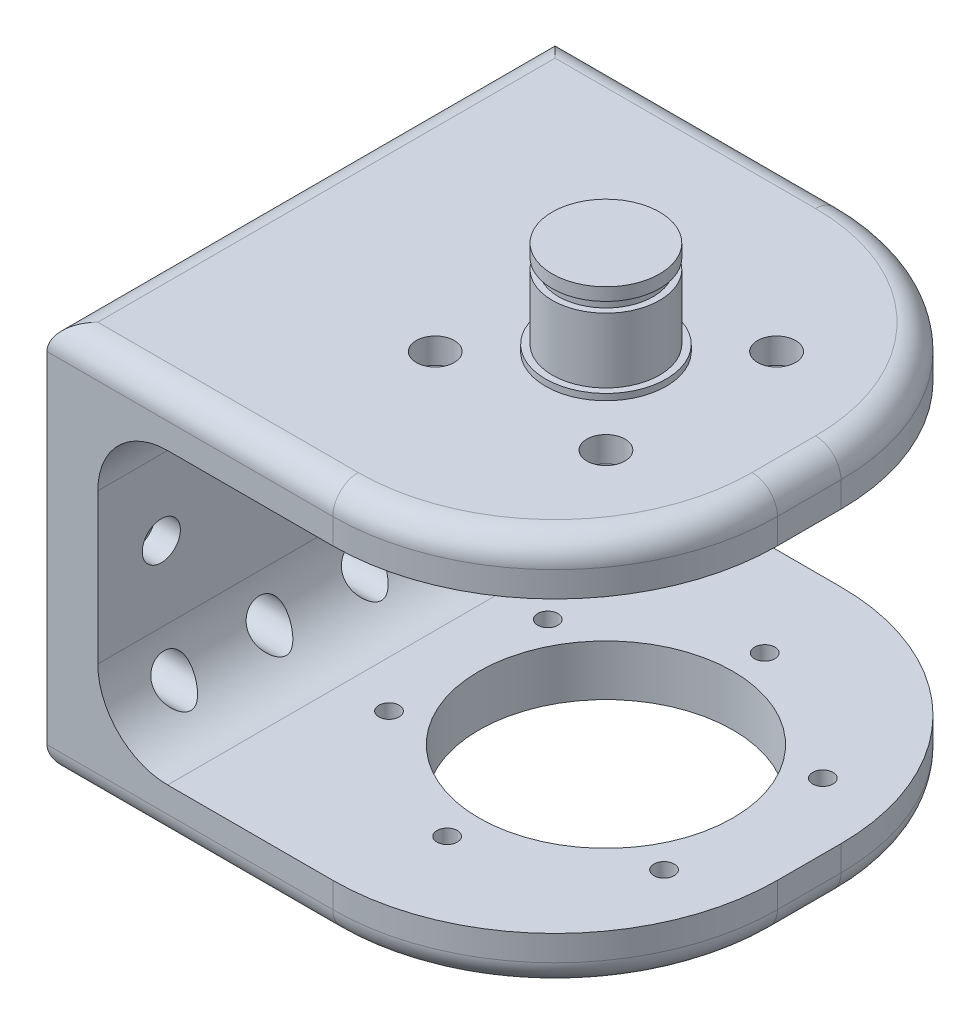
from build123d import *

# Parameters (mm, degrees)
SKETCH_1_W          = 80
SKETCH_1_H          = 80
EXTRUDE_1_DEPTH     = 8
SKETCH_2_W          = 8
SKETCH_2_H          = 80
EXTRUDE_2_DEPTH     = 53.6
SKETCH_5_W          = 80
SKETCH_5_H          = 8
EXTRUDE_3_DEPTH     = 72
SKETCH_4_R          = 1.6
SKETCH_4_R_2        = 20
CUT_EXTRUDE_1_DEPTH = 9
CUT_EXTRUDE_3_REACH = 63.6
SKETCH_7_R          = 1.6
FILLET_3_R          = 35
FILLET_4_R          = 11
SKETCH_6_R          = 1.6
CUT_EXTRUDE_2_DEPTH = 81
SKETCH_8_R          = 8.45
EXTRUDE_4_DEPTH     = 14.8
SKETCH_10_R         = 8.45
SKETCH_10_R_2       = 7.45
CUT_EXTRUDE_4_DEPTH = 1.6
CUT_EXTRUDE_5_REACH = 78
SKETCH_12_R         = 3
SKETCH_14_R         = 3
CUT_EXTRUDE_6_DEPTH = 4
SKETCH_15_R         = 3
CUT_EXTRUDE_7_DEPTH = 4
SKETCH_16_R         = 9.5
EXTRUDE_5_DEPTH     = 1
FILLET2_R           = 4


with BuildPart() as part:
    # 草图1 → 凸台-拉伸1 (new body)
    with BuildSketch(Plane(origin=(0, 0, 0), x_dir=(1, 0, 0), z_dir=(0, 1, 0))):
        Rectangle(SKETCH_1_W, SKETCH_1_H)
    extrude(amount=EXTRUDE_1_DEPTH)

    # 草图2 → 凸台-拉伸2 (add)
    with BuildSketch(Plane(origin=(0, 8, 0), x_dir=(1, 0, 0), z_dir=(0, 1, 0))):
        with Locations((-36, 0)):
            Rectangle(SKETCH_2_W, SKETCH_2_H)
    extrude(amount=EXTRUDE_2_DEPTH)

    # 草图5 → 凸台-拉伸3 (add, through all)
    with BuildSketch(Plane(origin=(-32, 0, 0), x_dir=(0, 0, -1), z_dir=(1, 0, 0))):
        with Locations((0, 57.6)):
            Rectangle(SKETCH_5_W, SKETCH_5_H)
    extrude(amount=EXTRUDE_3_DEPTH)

    # 草图4 → 切除-拉伸1 (cut, through all)
    with BuildSketch(Plane(origin=(0, 8, 0), x_dir=(1, 0, 0), z_dir=(0, 1, 0))):
        with Locations((8, 25)):
            Circle(SKETCH_4_R)
        with Locations((-13.650635095, 12.5)):
            Circle(SKETCH_4_R)
        with Locations((-13.650635095, -12.5)):
            Circle(SKETCH_4_R)
        with Locations((8, -25)):
            Circle(SKETCH_4_R)
        with Locations((8, 0)):
            Circle(SKETCH_4_R_2)
        with Locations((29.650635095, -12.5)):
            Circle(SKETCH_4_R)
        with Locations((29.650635095, 12.5)):
            Circle(SKETCH_4_R)
    extrude(amount=-CUT_EXTRUDE_1_DEPTH, mode=Mode.SUBTRACT)

    # 草图7 → 切除-拉伸3 (cut, up to next)
    with BuildSketch(Plane(origin=(0, 61.6, 0), x_dir=(1, 0, 0), z_dir=(0, 1, 0)), mode=Mode.PRIVATE) as cut_extrude_3_sk1:
        with Locations((-5.435028843, 13.435028843)):
            Circle(SKETCH_7_R)
    cut_extrude_3_tool1 = extrude(cut_extrude_3_sk1.sketch, amount=-CUT_EXTRUDE_3_REACH, mode=Mode.PRIVATE) & part.part
    add(cut_extrude_3_tool1.solids().sort_by_distance((-5.435029, 61.6, -13.435029))[0], mode=Mode.SUBTRACT)
    # 草图7 → 切除-拉伸3 (cut, up to next)
    with BuildSketch(Plane(origin=(0, 61.6, 0), x_dir=(1, 0, 0), z_dir=(0, 1, 0)), mode=Mode.PRIVATE) as cut_extrude_3_sk2:
        with Locations((21.435028843, 13.435028843)):
            Circle(SKETCH_7_R)
    cut_extrude_3_tool2 = extrude(cut_extrude_3_sk2.sketch, amount=-CUT_EXTRUDE_3_REACH, mode=Mode.PRIVATE) & part.part
    add(cut_extrude_3_tool2.solids().sort_by_distance((21.435029, 61.6, -13.435029))[0], mode=Mode.SUBTRACT)
    # 草图7 → 切除-拉伸3 (cut, up to next)
    with BuildSketch(Plane(origin=(0, 61.6, 0), x_dir=(1, 0, 0), z_dir=(0, 1, 0)), mode=Mode.PRIVATE) as cut_extrude_3_sk3:
        with Locations((21.435028843, -13.435028843)):
            Circle(SKETCH_7_R)
    cut_extrude_3_tool3 = extrude(cut_extrude_3_sk3.sketch, amount=-CUT_EXTRUDE_3_REACH, mode=Mode.PRIVATE) & part.part
    add(cut_extrude_3_tool3.solids().sort_by_distance((21.435029, 61.6, 13.435029))[0], mode=Mode.SUBTRACT)
    # 草图7 → 切除-拉伸3 (cut, up to next)
    with BuildSketch(Plane(origin=(0, 61.6, 0), x_dir=(1, 0, 0), z_dir=(0, 1, 0)), mode=Mode.PRIVATE) as cut_extrude_3_sk4:
        with Locations((-5.435028843, -13.435028843)):
            Circle(SKETCH_7_R)
    cut_extrude_3_tool4 = extrude(cut_extrude_3_sk4.sketch, amount=-CUT_EXTRUDE_3_REACH, mode=Mode.PRIVATE) & part.part
    add(cut_extrude_3_tool4.solids().sort_by_distance((-5.435029, 61.6, 13.435029))[0], mode=Mode.SUBTRACT)

    # 圆角3
    fillet_3_edges = [part.edges().sort_by_distance(p)[0] for p in [
        (40, 57.6, 40),
        (40, 57.6, -40),
        (40, 4, -40),
        (40, 4, 40),
    ]]
    fillet(fillet_3_edges, radius=FILLET_3_R)

    # 圆角4
    fillet_4_edges = [part.edges().sort_by_distance(p)[0] for p in [
        (-32, 8, 0),
        (-32, 53.6, 0),
    ]]
    fillet(fillet_4_edges, radius=FILLET_4_R)

    # 草图6 → 切除-拉伸2 (cut, through all)
    with BuildSketch(Plane.ZY.offset(40)):
        with Locations((-30, 48.6)):
            Circle(SKETCH_6_R)
        with Locations((30, 48.6)):
            Circle(SKETCH_6_R)
        with Locations((30, 13)):
            Circle(SKETCH_6_R)
        with Locations((-30, 13)):
            Circle(SKETCH_6_R)
        with Locations((-15, 13)):
            Circle(SKETCH_6_R)
        with Locations((0, 13)):
            Circle(SKETCH_6_R)
        with Locations((15, 13)):
            Circle(SKETCH_6_R)
        with Locations((-30, 30.8)):
            Circle(SKETCH_6_R)
        with Locations((30, 30.8)):
            Circle(SKETCH_6_R)
    extrude(amount=-CUT_EXTRUDE_2_DEPTH, mode=Mode.SUBTRACT)

    # 草图8 → 凸台-拉伸4 (add)
    with BuildSketch(Plane(origin=(0, 61.6, 0), x_dir=(1, 0, 0), z_dir=(0, 1, 0))):
        with Locations((8, 0)):
            Circle(SKETCH_8_R)
    extrude(amount=EXTRUDE_4_DEPTH)

    # 草图10 → 切除-拉伸4 (cut)
    with BuildSketch(Plane(origin=(0, 74.4, 0), x_dir=(1, 0, 0), z_dir=(0, 1, 0))):
        with Locations((8, 0)):
            Circle(SKETCH_10_R)
        with Locations((8, 0)):
            Circle(SKETCH_10_R_2, mode=Mode.SUBTRACT)
    extrude(amount=-CUT_EXTRUDE_4_DEPTH, mode=Mode.SUBTRACT)

    # 草图12 → 切除-拉伸5 (cut, up to next)
    with BuildSketch(Plane.ZY.offset(36), mode=Mode.PRIVATE) as cut_extrude_5_sk1:
        with Locations((-30, 48.6)):
            Circle(SKETCH_12_R)
    cut_extrude_5_tool1 = extrude(cut_extrude_5_sk1.sketch, amount=-CUT_EXTRUDE_5_REACH, mode=Mode.PRIVATE) & part.part
    add(cut_extrude_5_tool1.solids().sort_by_distance((-36, 48.6, -30))[0], mode=Mode.SUBTRACT)
    # 草图12 → 切除-拉伸5 (cut, up to next)
    with BuildSketch(Plane.ZY.offset(36), mode=Mode.PRIVATE) as cut_extrude_5_sk2:
        with Locations((30, 48.6)):
            Circle(SKETCH_12_R)
    cut_extrude_5_tool2 = extrude(cut_extrude_5_sk2.sketch, amount=-CUT_EXTRUDE_5_REACH, mode=Mode.PRIVATE) & part.part
    add(cut_extrude_5_tool2.solids().sort_by_distance((-36, 48.6, 30))[0], mode=Mode.SUBTRACT)
    # 草图12 → 切除-拉伸5 (cut, up to next)
    with BuildSketch(Plane.ZY.offset(36), mode=Mode.PRIVATE) as cut_extrude_5_sk3:
        with Locations((30, 13)):
            Circle(SKETCH_12_R)
    cut_extrude_5_tool3 = extrude(cut_extrude_5_sk3.sketch, amount=-CUT_EXTRUDE_5_REACH, mode=Mode.PRIVATE) & part.part
    add(cut_extrude_5_tool3.solids().sort_by_distance((-36, 13, 30))[0], mode=Mode.SUBTRACT)
    # 草图12 → 切除-拉伸5 (cut, up to next)
    with BuildSketch(Plane.ZY.offset(36), mode=Mode.PRIVATE) as cut_extrude_5_sk4:
        with Locations((-30, 13)):
            Circle(SKETCH_12_R)
    cut_extrude_5_tool4 = extrude(cut_extrude_5_sk4.sketch, amount=-CUT_EXTRUDE_5_REACH, mode=Mode.PRIVATE) & part.part
    add(cut_extrude_5_tool4.solids().sort_by_distance((-36, 13, -30))[0], mode=Mode.SUBTRACT)
    # 草图12 → 切除-拉伸5 (cut, up to next)
    with BuildSketch(Plane.ZY.offset(36), mode=Mode.PRIVATE) as cut_extrude_5_sk5:
        with Locations((-15, 13)):
            Circle(SKETCH_12_R)
    cut_extrude_5_tool5 = extrude(cut_extrude_5_sk5.sketch, amount=-CUT_EXTRUDE_5_REACH, mode=Mode.PRIVATE) & part.part
    add(cut_extrude_5_tool5.solids().sort_by_distance((-36, 13, -15))[0], mode=Mode.SUBTRACT)
    # 草图12 → 切除-拉伸5 (cut, up to next)
    with BuildSketch(Plane.ZY.offset(36), mode=Mode.PRIVATE) as cut_extrude_5_sk6:
        with Locations((0, 13)):
            Circle(SKETCH_12_R)
    cut_extrude_5_tool6 = extrude(cut_extrude_5_sk6.sketch, amount=-CUT_EXTRUDE_5_REACH, mode=Mode.PRIVATE) & part.part
    add(cut_extrude_5_tool6.solids().sort_by_distance((-36, 13, 0))[0], mode=Mode.SUBTRACT)
    # 草图12 → 切除-拉伸5 (cut, up to next)
    with BuildSketch(Plane.ZY.offset(36), mode=Mode.PRIVATE) as cut_extrude_5_sk7:
        with Locations((15, 13)):
            Circle(SKETCH_12_R)
    cut_extrude_5_tool7 = extrude(cut_extrude_5_sk7.sketch, amount=-CUT_EXTRUDE_5_REACH, mode=Mode.PRIVATE) & part.part
    add(cut_extrude_5_tool7.solids().sort_by_distance((-36, 13, 15))[0], mode=Mode.SUBTRACT)
    # 草图12 → 切除-拉伸5 (cut, up to next)
    with BuildSketch(Plane.ZY.offset(36), mode=Mode.PRIVATE) as cut_extrude_5_sk8:
        with Locations((-30, 30.8)):
            Circle(SKETCH_12_R)
    cut_extrude_5_tool8 = extrude(cut_extrude_5_sk8.sketch, amount=-CUT_EXTRUDE_5_REACH, mode=Mode.PRIVATE) & part.part
    add(cut_extrude_5_tool8.solids().sort_by_distance((-36, 30.8, -30))[0], mode=Mode.SUBTRACT)
    # 草图12 → 切除-拉伸5 (cut, up to next)
    with BuildSketch(Plane.ZY.offset(36), mode=Mode.PRIVATE) as cut_extrude_5_sk9:
        with Locations((30, 30.8)):
            Circle(SKETCH_12_R)
    cut_extrude_5_tool9 = extrude(cut_extrude_5_sk9.sketch, amount=-CUT_EXTRUDE_5_REACH, mode=Mode.PRIVATE) & part.part
    add(cut_extrude_5_tool9.solids().sort_by_distance((-36, 30.8, 30))[0], mode=Mode.SUBTRACT)

    # 草图14 → 切除-拉伸6 (cut)
    with BuildSketch(Plane(origin=(0, 61.6, 0), x_dir=(1, 0, 0), z_dir=(0, 1, 0))):
        with Locations((-5.435028843, 13.435028843)):
            Circle(SKETCH_14_R)
        with Locations((21.435028843, 13.435028843)):
            Circle(SKETCH_14_R)
        with Locations((21.435028843, -13.435028843)):
            Circle(SKETCH_14_R)
        with Locations((-5.435028843, -13.435028843)):
            Circle(SKETCH_14_R)
    extrude(amount=-CUT_EXTRUDE_6_DEPTH, mode=Mode.SUBTRACT)

    # 草图15 → 切除-拉伸7 (cut)
    with BuildSketch(Plane.XZ):
        with Locations((-13.650635095, 12.5)):
            Circle(SKETCH_15_R)
        with Locations((8, 25)):
            Circle(SKETCH_15_R)
        with Locations((29.650635095, 12.5)):
            Circle(SKETCH_15_R)
        with Locations((29.650635095, -12.5)):
            Circle(SKETCH_15_R)
        with Locations((8, -25)):
            Circle(SKETCH_15_R)
        with Locations((-13.650635095, -12.5)):
            Circle(SKETCH_15_R)
    extrude(amount=-CUT_EXTRUDE_7_DEPTH, mode=Mode.SUBTRACT)

    # 草图16 → 凸台-拉伸5 (add)
    with BuildSketch(Plane(origin=(0, 61.6, 0), x_dir=(1, 0, 0), z_dir=(0, 1, 0))):
        with Locations((8, 0)):
            Circle(SKETCH_16_R)
    extrude(amount=EXTRUDE_5_DEPTH)

    # Fillet2
    fillet2_edges = [part.edges().sort_by_distance(p)[0] for p in [
        (40, 0, 0),
        (29.748737342, 0, -29.748737342),
        (29.748737342, 0, 29.748737342),
        (-40, 61.6, 0),
        (-17.5, 61.6, 40),
        (-17.5, 0, 40),
        (-40, 0, 0),
        (40, 61.6, 0),
        (-17.5, 61.6, -40),
        (29.748737342, 61.6, 29.748737342),
        (29.748737342, 61.6, -29.748737342),
        (-17.5, 0, -40),
    ]]
    fillet(fillet2_edges, radius=FILLET2_R)


solid = part.part
